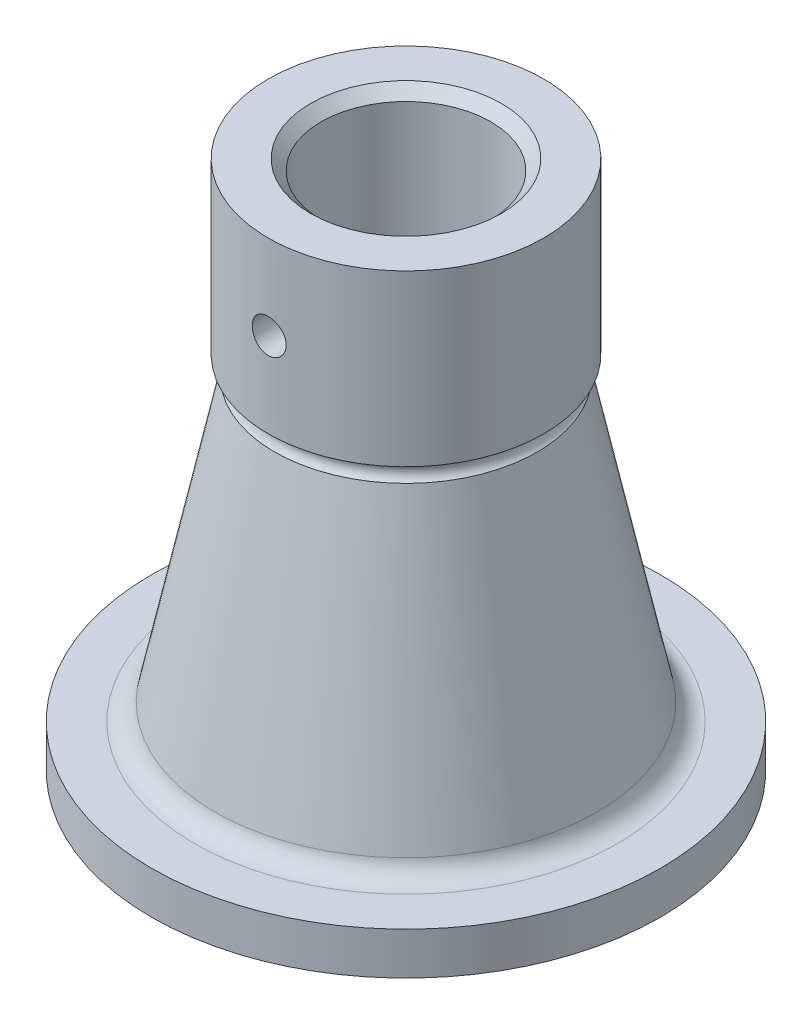
from build123d import *

# Parameters (mm, degrees)
CHAMFER1_SIZE      = 5
SKETCH2_R          = 8
CUT_EXTRUDE1_DEPTH = 120


with BuildPart() as part:
    # Sketch1 → Revolve1 (revolve)
    with BuildSketch(Plane.XY):
        with BuildLine():
            Line((40, 250), (65, 250))
            Line((65, 250), (65, 170))
            ThreePointArc((65, 170), (60.268530098, 166.616537216), (61.940561127, 161.045277028))
            Line((61.940561127, 161.045277028), (90, 27.937311241))
            ThreePointArc((90, 27.937311241), (93.485226827, 22.233826953), (99.784953504, 20))
            Line((99.784953504, 20), (120, 20))
            Line((120, 20), (120, 0))
            Line((120, 0), (80, 0))
            Line((80, 0), (45, 166.032500638))
            ThreePointArc((45, 166.032500638), (43.215449857, 168.917888595), (40, 170))
            Line((40, 170), (40, 250))
        make_face()
    revolve(axis=Axis((0, 107.637867538, 0), (0, -1, 0)))

    # Chamfer1
    chamfer1_edges = [part.edges().sort_by_distance(p)[0] for p in [
        (-40, 250, 0),
    ]]
    chamfer(chamfer1_edges, length=CHAMFER1_SIZE)

    # Sketch2 → Cut-Extrude1 (cut)
    with BuildSketch(Plane.XY):
        with Locations((0, 210)):
            Circle(SKETCH2_R)
    extrude(amount=CUT_EXTRUDE1_DEPTH, mode=Mode.SUBTRACT)


solid = part.part
